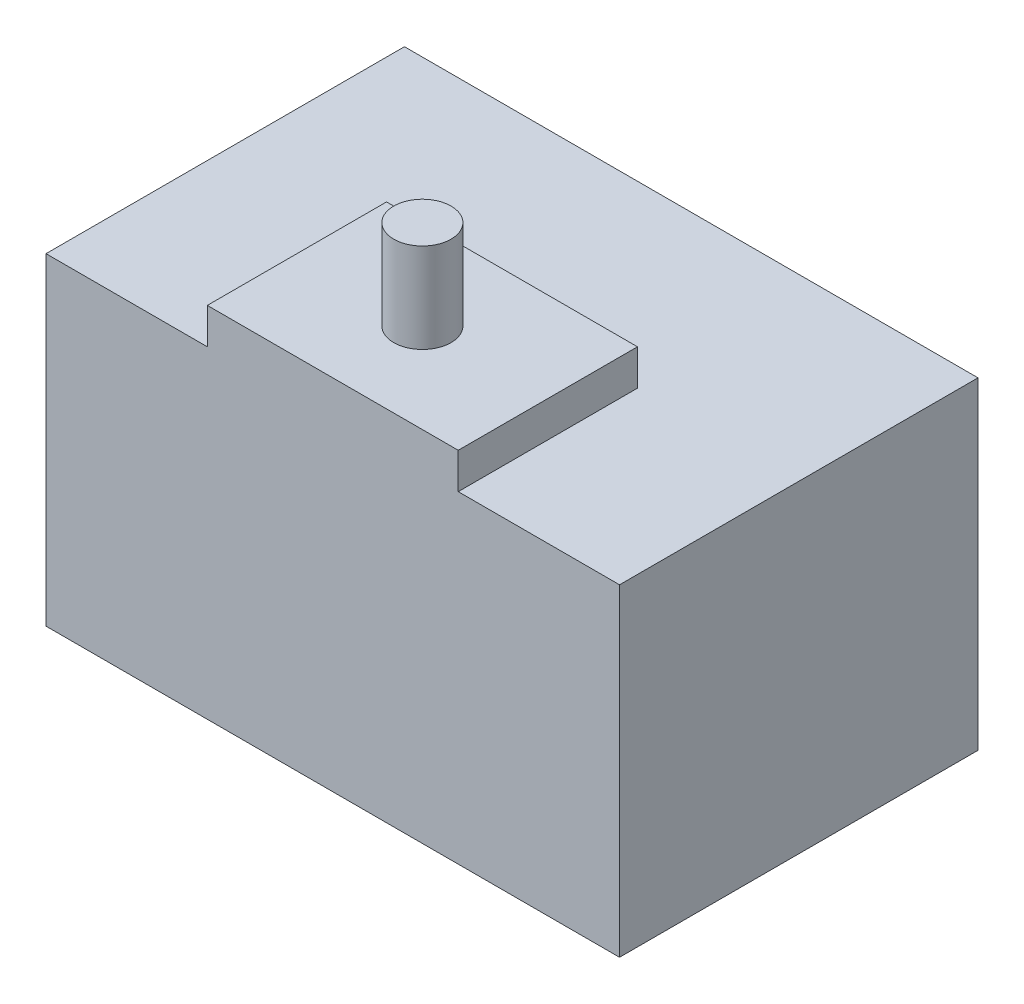
from build123d import *

# Parameters (mm, degrees)
SKETCH_1_W      = 1600
SKETCH_1_H      = 1000
EXTRUDE_1_DEPTH = 900
SKETCH_2_W      = 700
SKETCH_2_H      = 500
EXTRUDE_2_DEPTH = 100
SKETCH_5_R      = 80
EXTRUDE_5_DEPTH = 250


with BuildPart() as part:
    # 草图1 → 凸台-拉伸1 (new body)
    with BuildSketch(Plane(origin=(0, 0, 0), x_dir=(1, 0, 0), z_dir=(0, 1, 0))):
        Rectangle(SKETCH_1_W, SKETCH_1_H)
    extrude(amount=EXTRUDE_1_DEPTH)

    # 草图2 → 凸台-拉伸2 (add)
    with BuildSketch(Plane(origin=(0, 900, 0), x_dir=(1, 0, 0), z_dir=(0, 1, 0))):
        with Locations((0, -250)):
            Rectangle(SKETCH_2_W, SKETCH_2_H)
    extrude(amount=EXTRUDE_2_DEPTH)

    # 草图5 → 凸台-拉伸5 (add)
    with BuildSketch(Plane(origin=(0, 1000, 0), x_dir=(1, 0, 0), z_dir=(0, 1, 0))):
        with Locations((0, -250)):
            Circle(SKETCH_5_R)
    extrude(amount=EXTRUDE_5_DEPTH)


solid = part.part
